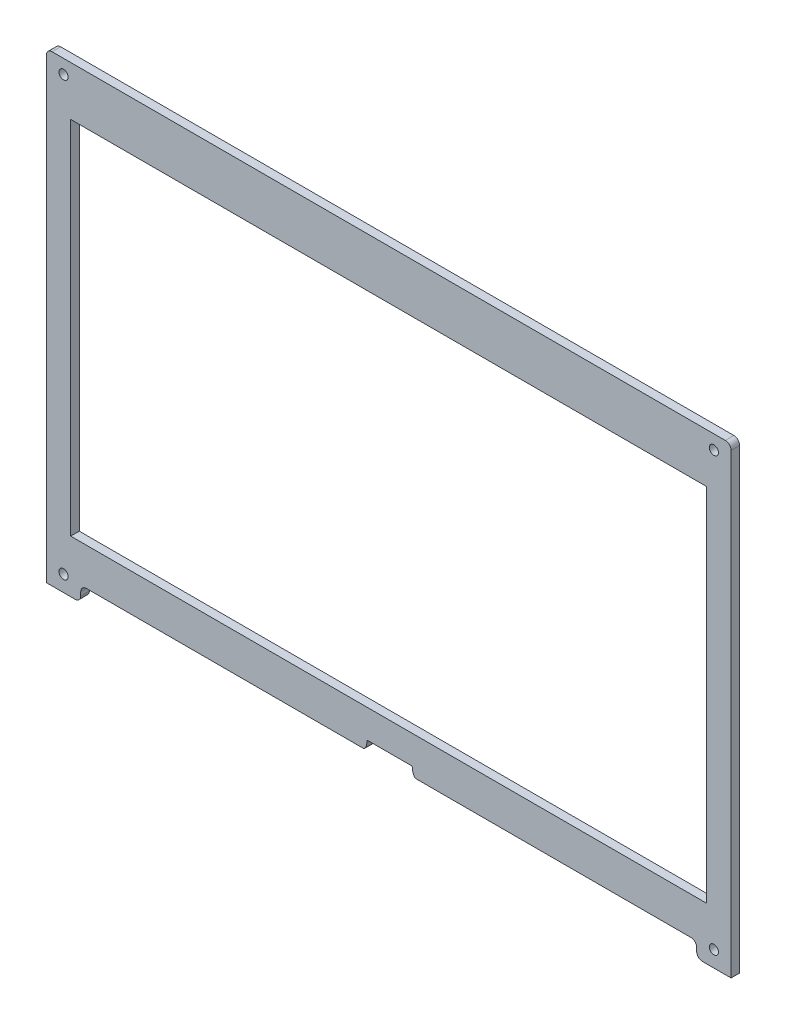
from build123d import *

# Parameters (mm, degrees)
SKETCH1_R           = 1.610492359
SKETCH1_R_2         = 1.59089725
SKETCH1_R_3         = 1.6
SKETCH1_W           = 222.015696088
SKETCH1_H           = 125.972340976
BOSS_EXTRUDE1_DEPTH = 3


with BuildPart() as part:
    # Sketch1 → Boss-Extrude1 (new body)
    with BuildSketch(Plane.XY):
        with BuildLine():
            Line((-105.5, -74.342560363), (-8.826077226, -74.342560363))
            ThreePointArc((-8.826077226, -74.342560363), (-8.626849156, -74.301174008), (-8.460609358, -74.183832695))
            ThreePointArc((-8.460609358, -74.183832695), (-7.882511931, -73.28221691), (-7.661371157, -72.234264423))
            Line((-7.661371157, -72.234264423), (-7.660812811, -71.693665015))
            ThreePointArc((-7.660812811, -71.693665015), (-7.514183841, -71.340445506), (-7.160813078, -71.194181429))
            Line((-7.160813078, -71.194181429), (7.839186922, -71.194181429))
            ThreePointArc((7.839186922, -71.194181429), (8.192557686, -71.340445506), (8.339186655, -71.693665015))
            Line((8.339186655, -71.693665015), (8.338670775, -72.154345161))
            ThreePointArc((8.338670775, -72.154345161), (8.546458509, -73.246362553), (9.140780516, -74.185755485))
            ThreePointArc((9.140780516, -74.185755485), (9.288714604, -74.294526792), (9.465938947, -74.342560363))
            Line((9.465938947, -74.342560363), (105.5, -74.342560363))
            ThreePointArc((105.5, -74.342560363), (106.914213562, -74.928346801), (107.5, -76.342560363))
            Line((107.5, -76.342560363), (107.5, -77.588833763))
            ThreePointArc((107.5, -77.588833763), (108.085786438, -79.003047325), (109.5, -79.588833763))
            Line((109.5, -79.588833763), (119.500003053, -79.588833763))
            Line((119.500003053, -79.588833763), (119.500003053, -78.888833763))
            Line((119.500003053, -78.888833763), (119.500003053, 79.91034623))
            ThreePointArc((119.500003053, 79.91034623), (118.912699712, 81.328214854), (117.494826949, 81.9155082))
            Line((117.494826949, 81.9155082), (-117.5, 81.913851764))
            ThreePointArc((-117.5, 81.913851764), (-118.914213562, 81.328065327), (-119.5, 79.913851764))
            Line((-119.5, 79.913851764), (-119.5, 0))
            Line((-119.5, 0), (-119.5, -78.888833763))
            Line((-119.5, -78.888833763), (-119.5, -79.588833763))
            Line((-119.5, -79.588833763), (-109.5, -79.588833763))
            ThreePointArc((-109.5, -79.588833763), (-108.085786438, -79.003047325), (-107.5, -77.588833763))
            Line((-107.5, -77.588833763), (-107.5, -76.342560363))
            ThreePointArc((-107.5, -76.342560363), (-106.914213562, -74.928346801), (-105.5, -74.342560363))
        make_face()
        with Locations((-113.5, -73.988833763)):
            Circle(SKETCH1_R, mode=Mode.SUBTRACT)
        with Locations((113.5, -73.988833763)):
            Circle(SKETCH1_R_2, mode=Mode.SUBTRACT)
        with Locations((-113.5, 77.014278693)):
            Circle(SKETCH1_R_3, mode=Mode.SUBTRACT)
        with Locations((0.009179053, 1.722083042)):
            Rectangle(SKETCH1_W, SKETCH1_H, mode=Mode.SUBTRACT)
        with Locations((113.5, 77.011166237)):
            Circle(SKETCH1_R_3, mode=Mode.SUBTRACT)
    extrude(amount=BOSS_EXTRUDE1_DEPTH)


solid = part.part
